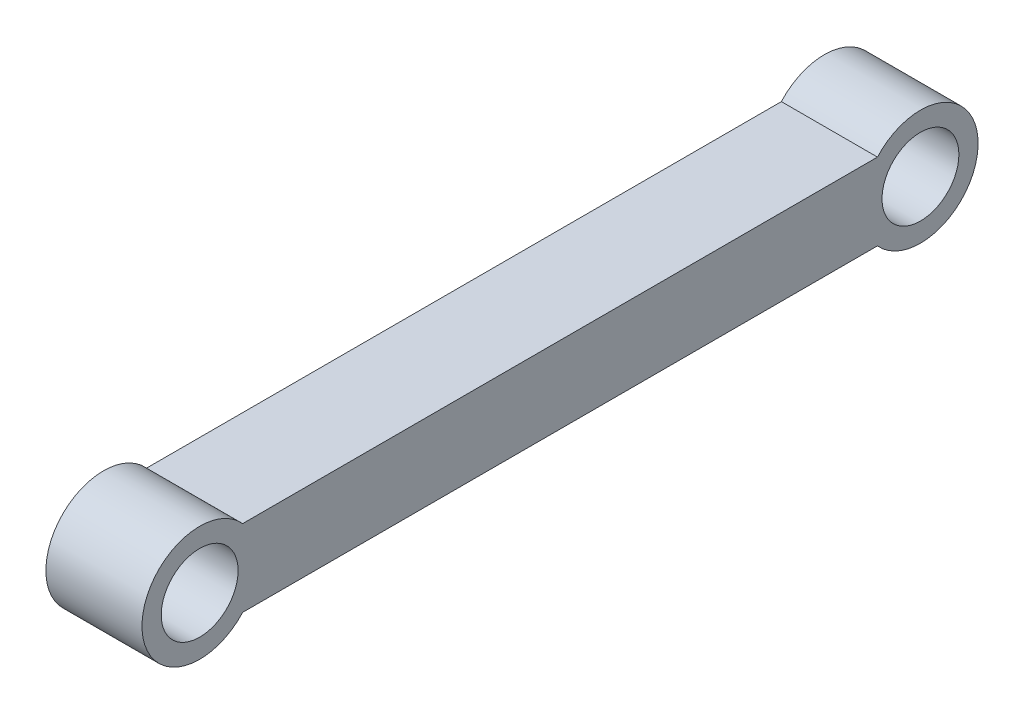
from build123d import *

# Parameters (mm, degrees)
LINKFRAME_R         = 40
BOSS_EXTRUDE1_DEPTH = 100


with BuildPart() as part:
    # LinkFrame → Boss-Extrude1 (new body)
    with BuildSketch(Plane(origin=(0, 0, 0), x_dir=(0, 0, -1), z_dir=(1, 0, 0))):
        with BuildLine():
            Line((-445.62417903, -186.263273145), (214.93310187, -186.263273145))
            ThreePointArc((214.93310187, -186.263273145), (319.65446142, -226.263273145), (214.93310187, -266.263273145))
            Line((214.93310187, -266.263273145), (-445.62417903, -266.263273145))
            ThreePointArc((-445.62417903, -266.263273145), (-550.34553858, -226.263273145), (-445.62417903, -186.263273145))
        make_face()
        with Locations((-490.34553858, -226.263273145)):
            Circle(LINKFRAME_R, mode=Mode.SUBTRACT)
        with Locations((259.65446142, -226.263273145)):
            Circle(LINKFRAME_R, mode=Mode.SUBTRACT)
    extrude(amount=BOSS_EXTRUDE1_DEPTH)


solid = part.part
